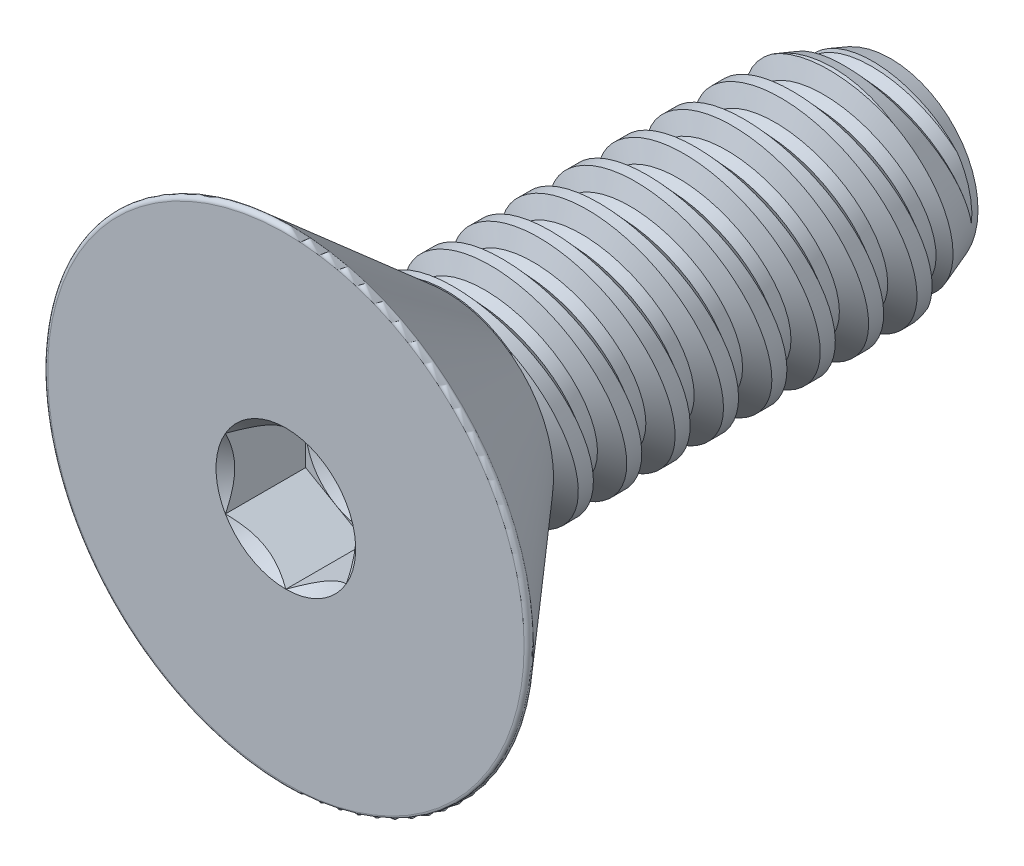
from build123d import *

# Parameters (mm, degrees)
SKETCH1_W          = 5.8293
SKETCH1_H          = 1.4224
LPATTERN1_COUNT    = 9
LPATTERN1_PITCH    = 0.635
LPATTERN2_COUNT    = 2
LPATTERN2_PITCH    = 0.635
SKETCH4_R          = 3.2385
EXTRUDE1_DEPTH     = 2.1082
FILLET1_R          = 0.0508
CUT_EXTRUDE1_DEPTH = 1.0541
SKETCH7_R          = 0.916543552
CUT_EXTRUDE4_DEPTH = 1.0541
CUT_EXTRUDE4_DRAFT = -45
SKETCH8_R          = 0.79375
CUT_EXTRUDE5_DEPTH = 0.351366667
CUT_EXTRUDE5_DRAFT = -60


with BuildPart() as part:
    # Sketch1 → Revolve1 (revolve)
    with BuildSketch(Plane(origin=(0, 0, 0), x_dir=(0, 0, -1), z_dir=(1, 0, 0)), mode=Mode.PRIVATE) as revolve1_sk:
        with Locations((2.91465, 0.7112)):
            Rectangle(SKETCH1_W, SKETCH1_H)
    revolve(revolve1_sk.sketch.rotate(Axis((0, 0, 0), (0, 0, 1)), 143.822582937), axis=Axis((0, 0, 0), (0, 0, 1)))

    # Sketch2 → Cut-Revolve1 (revolve, cut)
    with BuildSketch(Plane(origin=(0, 0, 0), x_dir=(0, 0, -1), z_dir=(1, 0, 0)), mode=Mode.PRIVATE) as cut_revolve1_sk:
        Polygon((0.077468538, 1.439692084), (0.619748307, 1.560736676), (0.500953883, 1.182057853), (0.346016806, 1.147473684), align=None)
    cut_revolve1 = revolve(cut_revolve1_sk.sketch.rotate(Axis((0, -0.152561988, 0), (0, 0.21785303258717018, -0.9759815859905214)), 180), axis=Axis((0, -0.152561988, 0), (0, 0.21785303258717018, -0.9759815859905214)), mode=Mode.SUBTRACT)

    # Sketch3 → Cut-Revolve2 (revolve, cut)
    with BuildSketch(Plane(origin=(0, 0, 0), x_dir=(0, 0, -1), z_dir=(1, 0, 0)), mode=Mode.PRIVATE) as cut_revolve2_sk:
        Polygon((5.8293, 1.147473684), (5.073946156, 1.4224), (5.8293, 1.4224), align=None)
    revolve(cut_revolve2_sk.sketch.rotate(Axis((0, 0, -5.073946156), (0, 0, 1)), 143.822582937), axis=Axis((0, 0, -5.073946156), (0, 0, 1)), mode=Mode.SUBTRACT)

    # LPattern1: Cut-Revolve1 ×9
    with Locations(*[(0, 0, -i * LPATTERN1_PITCH) for i in range(1, LPATTERN1_COUNT)]):
        add(cut_revolve1, mode=Mode.SUBTRACT)

    # LPattern2: Cut-Revolve1 ×2
    with Locations(*[(0, 0, i * LPATTERN2_PITCH) for i in range(1, LPATTERN2_COUNT)]):
        add(cut_revolve1, mode=Mode.SUBTRACT)

    # Sketch4 → Extrude1 (add)
    with BuildSketch(Plane.XY):
        Circle(SKETCH4_R)
    extrude(amount=EXTRUDE1_DEPTH)

    # Sketch9 → Cut-Revolve3 (revolve, cut)
    with BuildSketch(Plane(origin=(0, 0, 0), x_dir=(0, 0, -1), z_dir=(1, 0, 0)), mode=Mode.PRIVATE) as cut_revolve3_sk:
        Polygon((-2.1082, 3.2385), (0, 1.405869699), (0, 3.2385), align=None)
    revolve(cut_revolve3_sk.sketch.rotate(Axis((0, 0, 0), (0, 0, 1)), 270), axis=Axis((0, 0, 0), (0, 0, 1)), mode=Mode.SUBTRACT)

    # Fillet1
    fillet1_edges = [part.edges().sort_by_distance(p)[0] for p in [
        (-3.2385, 0, 2.1082),
    ]]
    fillet(fillet1_edges, radius=FILLET1_R)

    # Sketch6 → Cut-Extrude1 (cut)
    with BuildSketch(Plane.XY.offset(2.1082)):
        Polygon((0, -0.916543552), (0.79375, -0.458271776), (0.79375, 0.458271776), (0, 0.916543552), (-0.79375, 0.458271776), (-0.79375, -0.458271776), align=None)
    extrude(amount=-CUT_EXTRUDE1_DEPTH, mode=Mode.SUBTRACT)


with BuildPart() as cut_extrude4_tool:
    # Sketch7 → Cut-Extrude4 (with draft: the straight prism first)
    with BuildSketch(Plane.XY.offset(2.1082)):
        Circle(SKETCH7_R)
    extrude(amount=-CUT_EXTRUDE4_DEPTH)
    # Cut-Extrude4: the draft: its side faces are tilted about the plane it starts from
    cut_extrude4_sides = [cut_extrude4_tool.faces().sort_by_distance(p)[0] for p in [
        (-0.916543552, 0, 1.58115),
    ]]
    draft(cut_extrude4_sides, Plane.XY.offset(2.1082), CUT_EXTRUDE4_DRAFT)


with BuildPart() as part_1:
    add(part.part)

    # Cut-Extrude4: cut by cut_extrude4_tool
    add(cut_extrude4_tool.part, mode=Mode.SUBTRACT)


with BuildPart() as cut_extrude5_tool:
    # Sketch8 → Cut-Extrude5 (with draft: the straight prism first)
    with BuildSketch(Plane.XY.offset(1.0541)):
        Circle(SKETCH8_R)
    extrude(amount=-CUT_EXTRUDE5_DEPTH)
    # Cut-Extrude5: the draft: its side faces are tilted about the plane it starts from
    cut_extrude5_sides = [cut_extrude5_tool.faces().sort_by_distance(p)[0] for p in [
        (-0.79375, 0, 0.878416667),
    ]]
    draft(cut_extrude5_sides, Plane.XY.offset(1.0541), CUT_EXTRUDE5_DRAFT)


with BuildPart() as part_2:
    add(part_1.part)

    # Cut-Extrude5: cut by cut_extrude5_tool
    add(cut_extrude5_tool.part, mode=Mode.SUBTRACT)


solid = part_2.part
